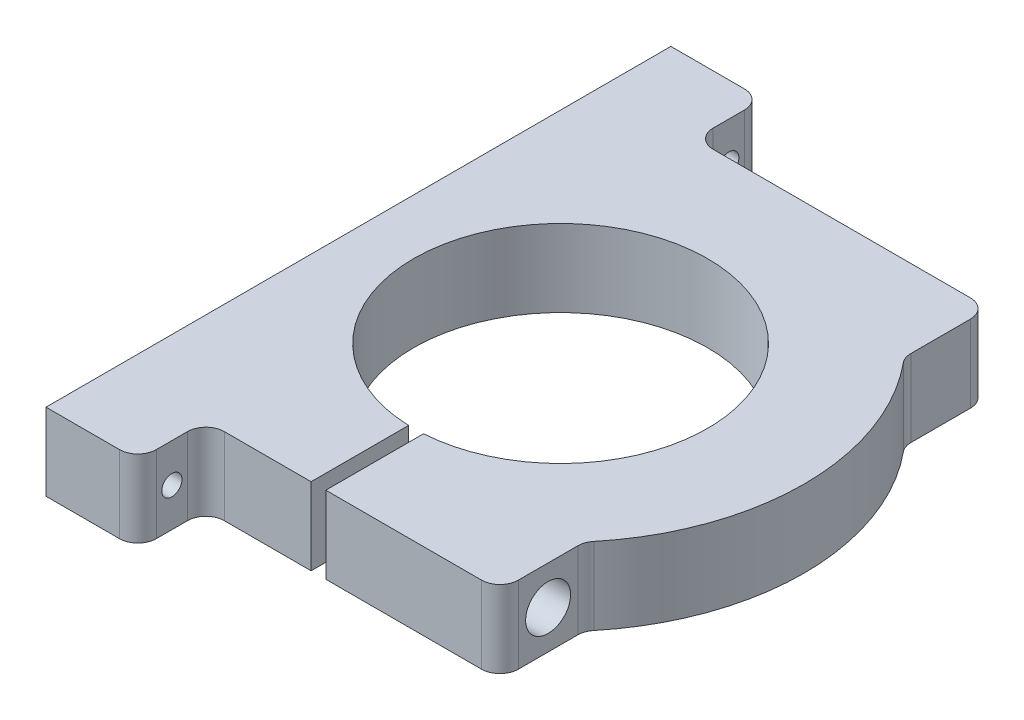
from build123d import *

# Parameters (mm, degrees)
BOSS_EXTRUDE2_DEPTH                     = 21
FILLET2_R                               = 5
M5_CLEARANCE_HOLE1_D                    = 5.5
CBORE_FOR_M5_HEX_HEAD_BOLT1_D           = 5.5
CBORE_FOR_M5_HEX_HEAD_BOLT1_DEPTH       = 47.375
CBORE_FOR_M5_HEX_HEAD_BOLT1_CBORE_D     = 12.238
CBORE_FOR_M5_HEX_HEAD_BOLT1_CBORE_DEPTH = 23.5
TAP_DRILL_FOR_M5_TAP1_D                 = 4.2
TAP_DRILL_FOR_M5_TAP1_DEPTH             = 53.625


with BuildPart() as part:
    # Sketch1 → Boss-Extrude2 (new body)
    with BuildSketch(Plane(origin=(0, 0, -219.72), x_dir=(1, 0, 0), z_dir=(0, -1, 0))):
        with BuildLine():
            Line((17.325408024, -30.717863594), (-30.049591976, -30.717863594))
            Line((-30.049591976, -30.717863594), (-30.049591976, -57.304089343))
            ThreePointArc((-30.049591976, -57.304089343), (-33.300374886, -137.212968242), (-34.049591976, -57.241503392))
            Line((-34.049591976, -57.241503392), (-34.049591976, -30.717863594))
            Line((-34.049591976, -30.717863594), (-62.674591976, -30.717863594))
            Line((-62.674591976, -30.717863594), (-62.674591976, -12.217863594))
            Line((-62.674591976, -12.217863594), (-87.674591976, -12.217863594))
            Line((-87.674591976, -12.217863594), (-87.674591976, -182.217863594))
            Line((-87.674591976, -182.217863594), (-62.674591976, -182.217863594))
            Line((-62.674591976, -182.217863594), (-62.674591976, -163.717863594))
            Line((-62.674591976, -163.717863594), (17.325408024, -163.717863594))
            Line((17.325408024, -163.717863594), (17.325408024, -140.681210221))
            ThreePointArc((17.325408024, -140.681210221), (33.575408024, -97.217863594), (17.325408024, -53.754516967))
            Line((17.325408024, -53.754516967), (17.325408024, -30.717863594))
        make_face()
    extrude(amount=BOSS_EXTRUDE2_DEPTH)

    # Fillet2
    fillet2_edges = [part.edges().sort_by_distance(p)[0] for p in [
        (-62.674591976, -10.5, -250.437863594),
        (-62.674591976, -10.5, -231.937863594),
        (-62.674591976, -10.5, -401.937863594),
        (-62.674591976, -10.5, -383.437863594),
        (17.325408024, -10.5, -383.437863594),
        (17.325408024, -10.5, -360.401210221),
        (17.325408024, -10.5, -273.474516967),
        (17.325408024, -10.5, -250.437863594),
    ]]
    fillet(fillet2_edges, radius=FILLET2_R)

    # M5 Clearance Hole1 (through all)
    with Locations(Plane(origin=(17.325408024, 0, 0), x_dir=(0, 0, -1), z_dir=(1, 0, 0))):
        with Locations((392.687863594, -10.5), (241.187863594, -10.5)):
            Hole(M5_CLEARANCE_HOLE1_D / 2)

    # CBORE for M5 Hex Head Bolt1
    with Locations(Plane(origin=(17.325408024, 0, 0), x_dir=(0, 0, -1), z_dir=(1, 0, 0))):
        with Locations((263.540774929, -10.5)):
            CounterBoreHole(CBORE_FOR_M5_HEX_HEAD_BOLT1_D / 2, CBORE_FOR_M5_HEX_HEAD_BOLT1_CBORE_D / 2, CBORE_FOR_M5_HEX_HEAD_BOLT1_CBORE_DEPTH, depth=CBORE_FOR_M5_HEX_HEAD_BOLT1_DEPTH)

    # Tap Drill for M5 Tap1
    with Locations(Plane(origin=(-34.049591976, 0, 0), x_dir=(0, 0, -1), z_dir=(1, 0, 0))):
        with Locations((263.540774929, -10.5)):
            Hole(TAP_DRILL_FOR_M5_TAP1_D / 2, depth=TAP_DRILL_FOR_M5_TAP1_DEPTH)


solid = part.part
